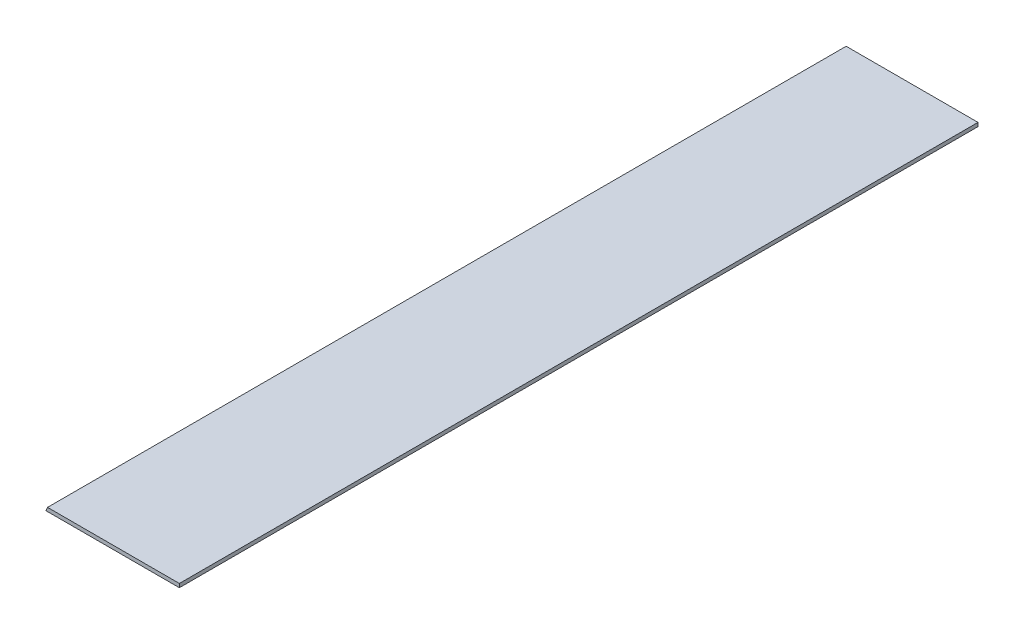
from build123d import *

# Parameters (mm, degrees)
BOSS_EXTRUDE1_DEPTH = 508


with BuildPart() as part:
    # Sketch1 → Boss-Extrude1 (new body)
    with BuildSketch(Plane.XY):
        Polygon((0, 0), (0.978455277, 2.3622), (84.836, 2.3622), (84.836, 0), align=None)
    extrude(amount=BOSS_EXTRUDE1_DEPTH)


solid = part.part
